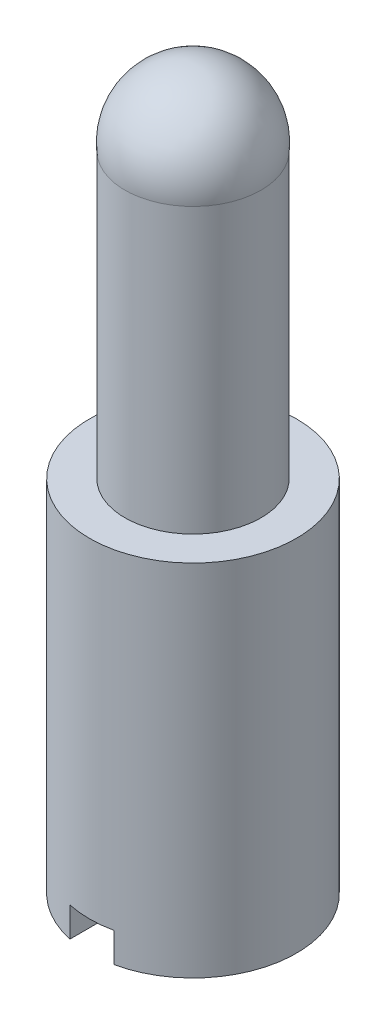
from build123d import *

# Parameters (mm, degrees)
SKETCH2_W               = 1.1684
SKETCH2_H               = 0.7874
CUT_EXTRUDE1_DEPTH      = 3.7432
CUT_EXTRUDE1_DEPTH_BACK = 3.7432


with BuildPart() as part:
    # Sketch1 → Revolve1 (revolve)
    with BuildSketch(Plane.XY):
        with BuildLine():
            Line((0, 0), (0, 19.05))
            ThreePointArc((0, 19.05), (1.348059913, 18.449540529), (1.8034, 17.045801767))
            Line((1.8034, 17.045801767), (1.8034, 9.525))
            Line((1.8034, 9.525), (2.7432, 9.525))
            Line((2.7432, 9.525), (2.7432, 0))
            Line((2.7432, 0), (0, 0))
        make_face()
    revolve(axis=Axis((0, 0, 0), (0, 1, 0)))

    # Sketch2 → Cut-Extrude1 (cut, two sides)
    with BuildSketch(Plane.XY) as cut_extrude1_sk:
        with Locations((0, 0.3937)):
            Rectangle(SKETCH2_W, SKETCH2_H)
    extrude(amount=CUT_EXTRUDE1_DEPTH, mode=Mode.SUBTRACT)
    extrude(cut_extrude1_sk.sketch, amount=-CUT_EXTRUDE1_DEPTH_BACK, mode=Mode.SUBTRACT)


solid = part.part
